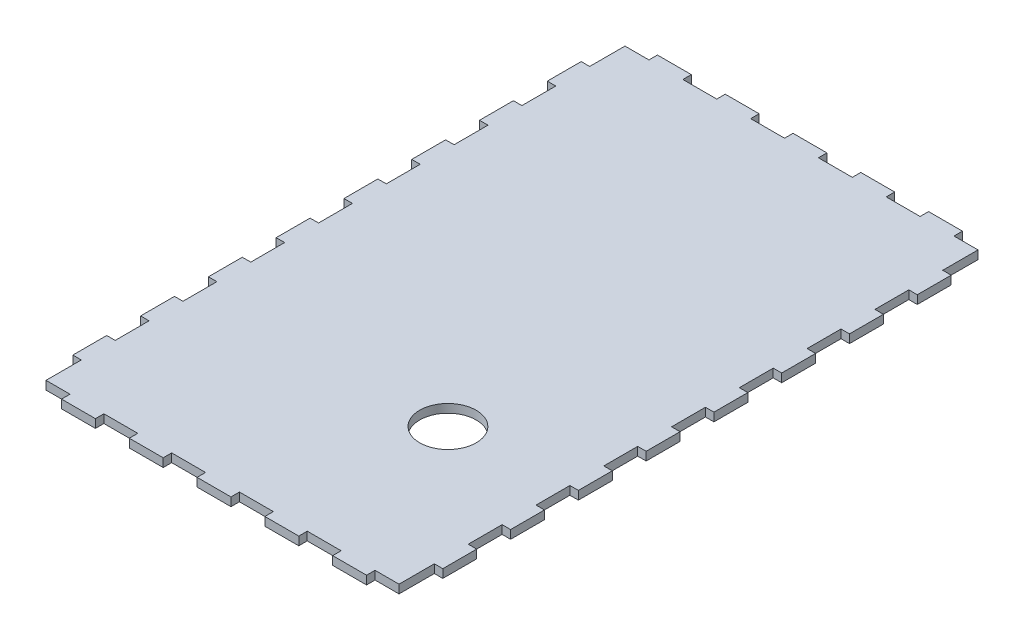
from build123d import *

# Parameters (mm, degrees)
SKETCH3_W           = 125
SKETCH3_H           = 205
BOSS_EXTRUDE1_DEPTH = 3
SKETCH5_W           = 12
SKETCH5_H           = 3
SKETCH5_W_2         = 3
SKETCH5_H_2         = 12
BOSS_EXTRUDE2_DEPTH = 3
SKETCH6_R           = 10
CUT_EXTRUDE1_DEPTH  = 6


with BuildPart() as part:
    # Sketch3 → Boss-Extrude1 (new body)
    with BuildSketch(Plane(origin=(0, 0, 0), x_dir=(1, 0, 0), z_dir=(0, 1, 0))):
        Rectangle(SKETCH3_W, SKETCH3_H)
    extrude(amount=BOSS_EXTRUDE1_DEPTH)

    # Sketch5 → Boss-Extrude2 (add)
    with BuildSketch(Plane(origin=(0, 3, 0), x_dir=(1, 0, 0), z_dir=(0, 1, 0))):
        with Locations((24, -104)):
            Rectangle(SKETCH5_W, SKETCH5_H)
        with Locations((0, -104)):
            Rectangle(SKETCH5_W, SKETCH5_H)
        with Locations((-64, -84)):
            Rectangle(SKETCH5_W_2, SKETCH5_H_2)
        with Locations((-64, -60)):
            Rectangle(SKETCH5_W_2, SKETCH5_H_2)
        with Locations((-64, -12)):
            Rectangle(SKETCH5_W_2, SKETCH5_H_2)
        with Locations((64, -84)):
            Rectangle(SKETCH5_W_2, SKETCH5_H_2)
        with Locations((64, -36)):
            Rectangle(SKETCH5_W_2, SKETCH5_H_2)
        with Locations((64, -12)):
            Rectangle(SKETCH5_W_2, SKETCH5_H_2)
        with Locations((64, 12)):
            Rectangle(SKETCH5_W_2, SKETCH5_H_2)
        with Locations((64, 36)):
            Rectangle(SKETCH5_W_2, SKETCH5_H_2)
        with Locations((64, 84)):
            Rectangle(SKETCH5_W_2, SKETCH5_H_2)
        with Locations((24, 104)):
            Rectangle(SKETCH5_W, SKETCH5_H)
        with Locations((0, 104)):
            Rectangle(SKETCH5_W, SKETCH5_H)
        with Locations((-24, 104)):
            Rectangle(SKETCH5_W, SKETCH5_H)
        with Locations((-48, 104)):
            Rectangle(SKETCH5_W, SKETCH5_H)
        with Locations((-64, 36)):
            Rectangle(SKETCH5_W_2, SKETCH5_H_2)
        with Locations((-64, 12)):
            Rectangle(SKETCH5_W_2, SKETCH5_H_2)
        with Locations((48, -104)):
            Rectangle(SKETCH5_W, SKETCH5_H)
        with Locations((-24, -104)):
            Rectangle(SKETCH5_W, SKETCH5_H)
        with Locations((-48, -104)):
            Rectangle(SKETCH5_W, SKETCH5_H)
        with Locations((-64, -36)):
            Rectangle(SKETCH5_W_2, SKETCH5_H_2)
        with Locations((64, -60)):
            Rectangle(SKETCH5_W_2, SKETCH5_H_2)
        with Locations((64, 60)):
            Rectangle(SKETCH5_W_2, SKETCH5_H_2)
        with Locations((48, 104)):
            Rectangle(SKETCH5_W, SKETCH5_H)
        with Locations((-64, 84)):
            Rectangle(SKETCH5_W_2, SKETCH5_H_2)
        with Locations((-64, 60)):
            Rectangle(SKETCH5_W_2, SKETCH5_H_2)
    extrude(amount=-BOSS_EXTRUDE2_DEPTH)

    # Sketch6 → Cut-Extrude1 (cut)
    with BuildSketch(Plane(origin=(0, 3, 0), x_dir=(1, 0, 0), z_dir=(0, 1, 0))):
        with Locations((22.817541634, -45.5)):
            Circle(SKETCH6_R)
    extrude(amount=-CUT_EXTRUDE1_DEPTH, mode=Mode.SUBTRACT)


solid = part.part
